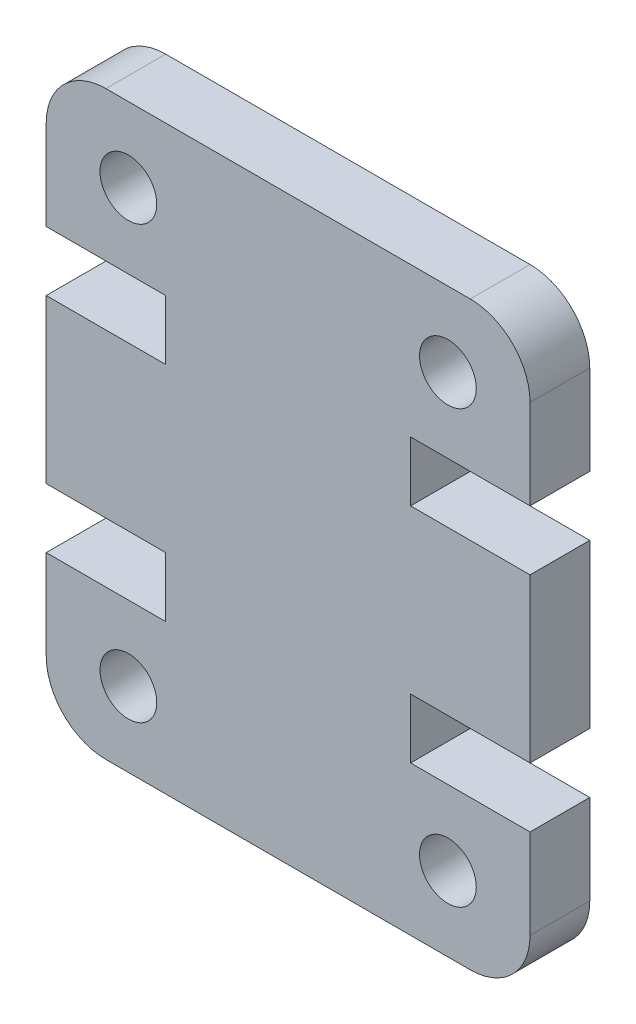
from build123d import *

# Parameters (mm, degrees)
SKETCH2_R           = 0.95
BOSS_EXTRUDE1_DEPTH = 4
SKETCH3_W           = 16.2
SKETCH3_H           = 19.455
CUT_EXTRUDE1_DEPTH  = 2


with BuildPart() as part:
    # Sketch2 → Boss-Extrude1 (new body)
    with BuildSketch(Plane.XY):
        with BuildLine():
            Line((0, 7), (0, 12.455))
            Line((0, 12.455), (4, 12.455))
            Line((4, 12.455), (4, 14.455))
            Line((4, 14.455), (0, 14.455))
            Line((0, 14.455), (0, 17.455))
            ThreePointArc((0, 17.455), (0.585786438, 18.869213562), (2, 19.455))
            Line((2, 19.455), (14.2, 19.455))
            ThreePointArc((14.2, 19.455), (15.614213562, 18.869213562), (16.2, 17.455))
            Line((16.2, 17.455), (16.2, 14.455))
            Line((16.2, 14.455), (12.2, 14.455))
            Line((12.2, 14.455), (12.2, 12.455))
            Line((12.2, 12.455), (16.2, 12.455))
            Line((16.2, 12.455), (16.2, 7))
            Line((16.2, 7), (12.2, 7))
            Line((12.2, 7), (12.2, 5))
            Line((12.2, 5), (16.2, 5))
            Line((16.2, 5), (16.2, 2))
            ThreePointArc((16.2, 2), (15.614213562, 0.585786438), (14.2, 0))
            Line((14.2, 0), (2, 0))
            ThreePointArc((2, 0), (0.585786438, 0.585786438), (0, 2))
            Line((0, 2), (0, 5))
            Line((0, 5), (4, 5))
            Line((4, 5), (4, 7))
            Line((4, 7), (0, 7))
        make_face()
        with Locations((13.45, 2.5)):
            Circle(SKETCH2_R, mode=Mode.SUBTRACT)
        with Locations((2.75, 16.955)):
            Circle(SKETCH2_R, mode=Mode.SUBTRACT)
        with Locations((2.75, 2.5)):
            Circle(SKETCH2_R, mode=Mode.SUBTRACT)
        with Locations((13.45, 16.955)):
            Circle(SKETCH2_R, mode=Mode.SUBTRACT)
    extrude(amount=BOSS_EXTRUDE1_DEPTH)

    # Sketch3 → Cut-Extrude1 (cut)
    with BuildSketch(Plane.XY.offset(4)):
        with Locations((8.1, 9.7275)):
            Rectangle(SKETCH3_W, SKETCH3_H)
    extrude(amount=-CUT_EXTRUDE1_DEPTH, mode=Mode.SUBTRACT)


solid = part.part
